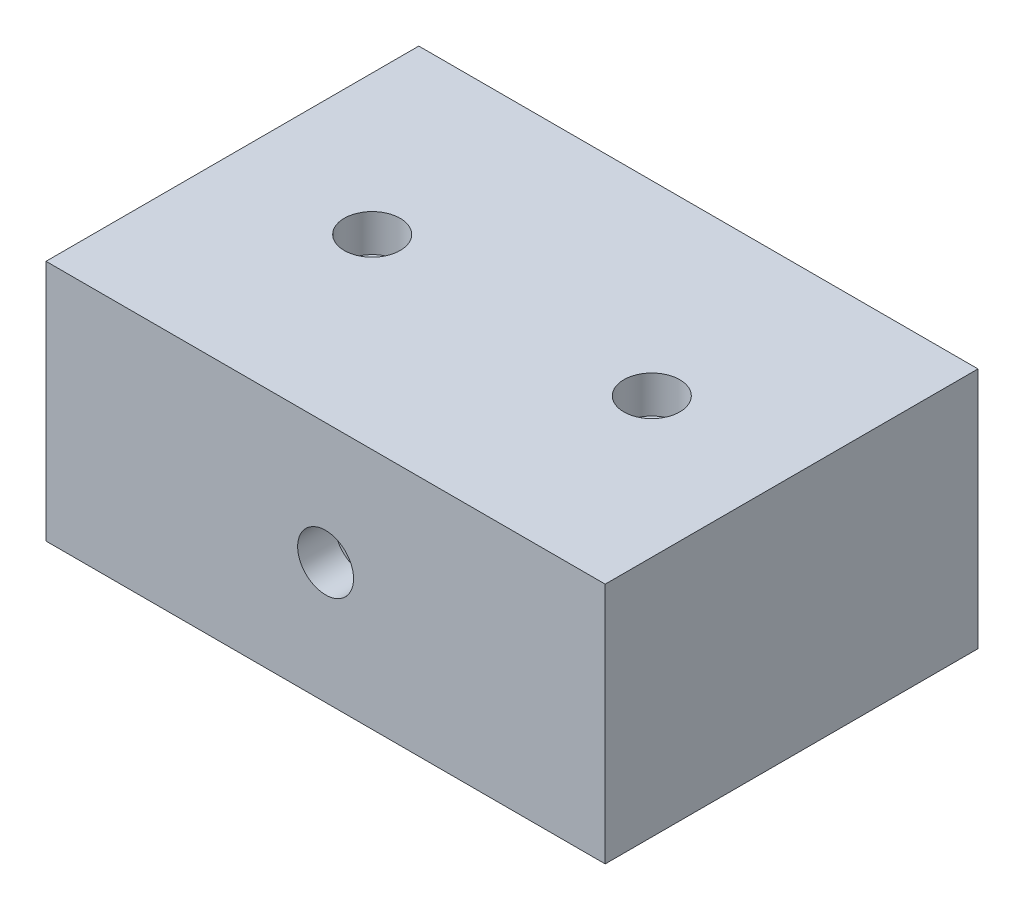
from build123d import *

# Parameters (mm, degrees)
SKETCH1_W           = 30
SKETCH1_H           = 13
BOSS_EXTRUDE1_DEPTH = 20
SKETCH2_R           = 1.5
CUT_EXTRUDE1_DEPTH  = 2
SKETCH3_R           = 1.5
CUT_EXTRUDE2_DEPTH  = 2


with BuildPart() as part:
    # Sketch1 → Boss-Extrude1 (new body)
    with BuildSketch(Plane.XY):
        with Locations((15, 6.5)):
            Rectangle(SKETCH1_W, SKETCH1_H)
    extrude(amount=BOSS_EXTRUDE1_DEPTH)

    # Sketch2 → Cut-Extrude1 (cut)
    with BuildSketch(Plane.XY.offset(20)):
        with Locations((15, 6.5)):
            Circle(SKETCH2_R)
    extrude(amount=-CUT_EXTRUDE1_DEPTH, mode=Mode.SUBTRACT)

    # Sketch3 → Cut-Extrude2 (cut)
    with BuildSketch(Plane(origin=(0, 13, 0), x_dir=(1, 0, 0), z_dir=(0, 1, 0))):
        with Locations((7.5, -10)):
            Circle(SKETCH3_R)
        with Locations((22.5, -10)):
            Circle(SKETCH3_R)
    extrude(amount=-CUT_EXTRUDE2_DEPTH, mode=Mode.SUBTRACT)


solid = part.part
